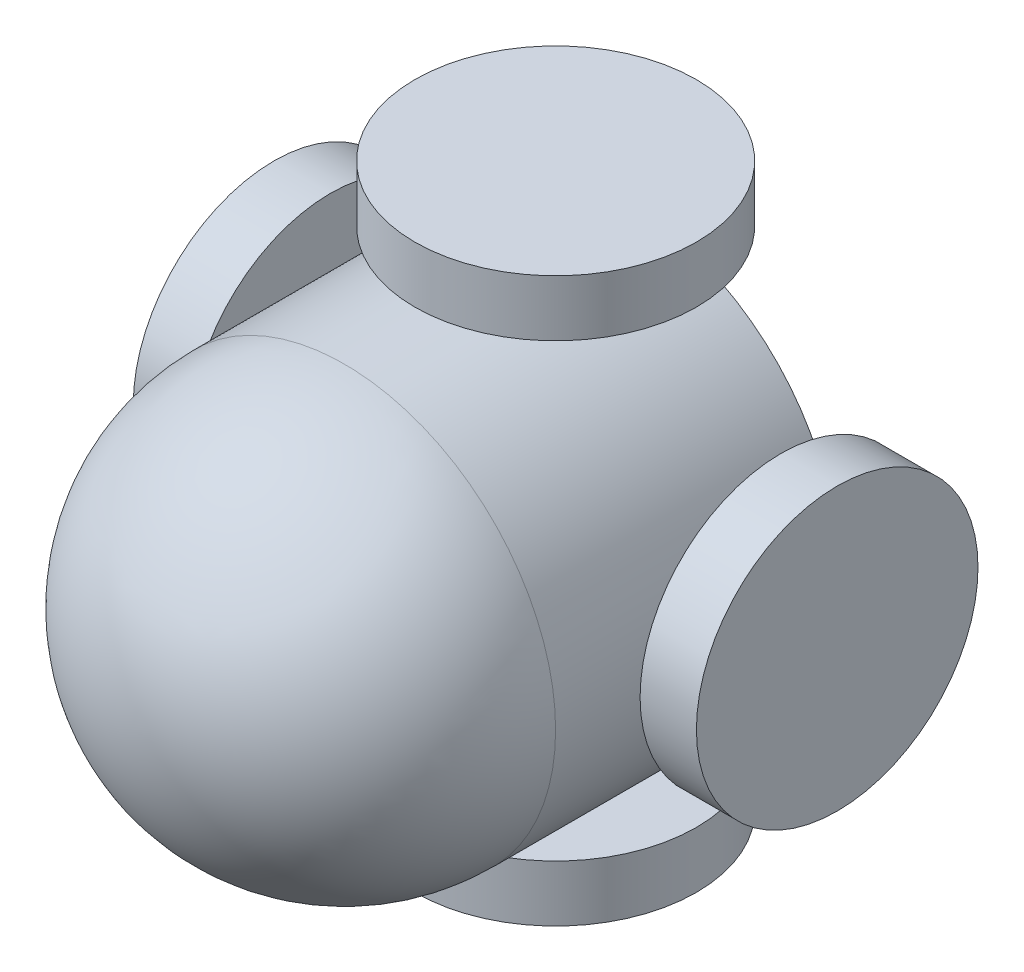
from build123d import *

# Parameters (mm, degrees)
BOSS_EXTRUDE1_START = 0.5
SKETCH1_R           = 1.5
BOSS_EXTRUDE1_DEPTH = 2
REVOLVE1_ANGLE      = 180
SKETCH3_R           = 0.25
BOSS_EXTRUDE2_DEPTH = 2
SKETCH4_R           = 1
BOSS_EXTRUDE3_DEPTH = 0.4
CIRPATTERN2_COUNT   = 4


with BuildPart() as part:
    # Sketch1 → Boss-Extrude1 (new body)
    with BuildSketch(Plane.XY.offset(BOSS_EXTRUDE1_START)):
        Circle(SKETCH1_R)
    extrude(amount=BOSS_EXTRUDE1_DEPTH)

    # Sketch2 → Revolve1 (revolve)
    with BuildSketch(Plane.XY.offset(2.5)):
        with BuildLine():
            Line((1.5, 0), (-1.5, 0))
            ThreePointArc((-1.5, 0), (0, 1.5), (1.5, 0))
        make_face()
    revolve(axis=Axis((1.5, 0, 2.5), (1, 0, 0)), revolution_arc=REVOLVE1_ANGLE)

    # Sketch3 → Boss-Extrude2 (add)
    with BuildSketch(Plane(origin=(0, 0, 0), x_dir=(0, 0, -1), z_dir=(1, 0, 0))):
        with Locations((-1, 0)):
            Circle(SKETCH3_R)
    boss_extrude2 = extrude(amount=BOSS_EXTRUDE2_DEPTH)

    # Sketch4 → Boss-Extrude3 (add)
    with BuildSketch(Plane(origin=(2, 0, 0), x_dir=(0, 0, -1), z_dir=(1, 0, 0))):
        with Locations((-1, 0)):
            Circle(SKETCH4_R)
    boss_extrude3 = extrude(amount=-BOSS_EXTRUDE3_DEPTH)

    # CirPattern2: Boss-Extrude2, Boss-Extrude3 ×4 about axis
    cirpattern2_axis = Axis((0, 0, 0), (0, 0, 1))
    for i in range(1, CIRPATTERN2_COUNT):
        add(boss_extrude2.rotate(cirpattern2_axis, i * 360 / CIRPATTERN2_COUNT))
        add(boss_extrude3.rotate(cirpattern2_axis, i * 360 / CIRPATTERN2_COUNT))


solid = part.part
